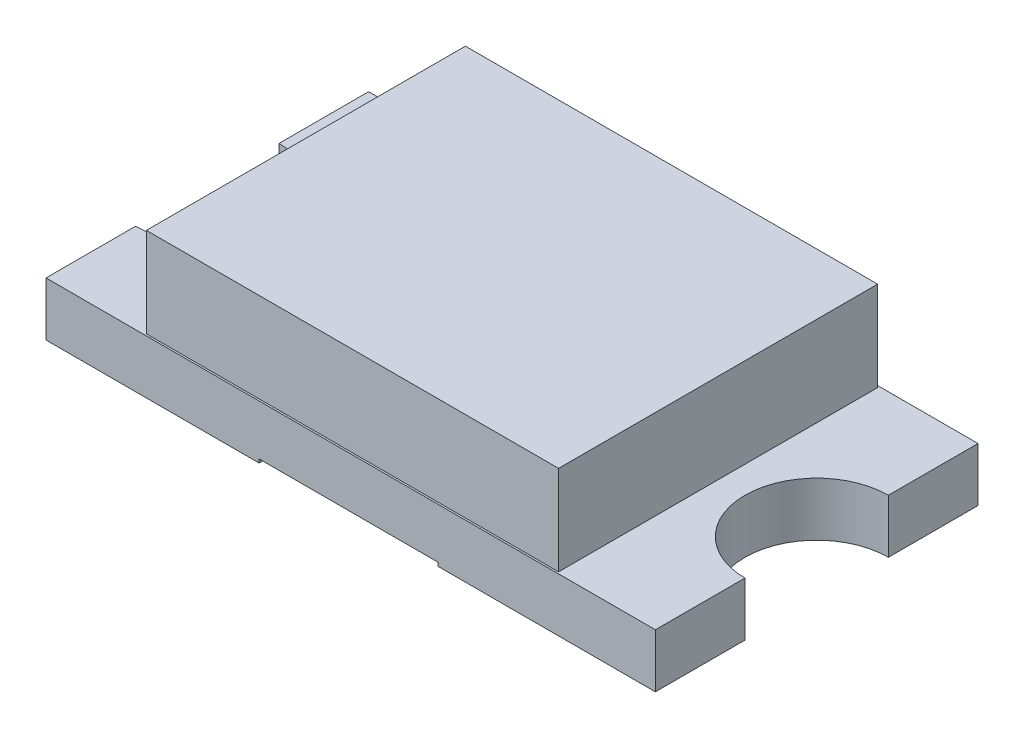
from build123d import *

# Parameters (mm, degrees)
SKETCH1_W           = 1.7
SKETCH1_H           = 0.9
BOSS_EXTRUDE1_DEPTH = 0.15
SKETCH2_R           = 0.2
CUT_EXTRUDE1_DEPTH  = 1.15
SKETCH3_W           = 1.15
SKETCH3_H           = 0.89
BOSS_EXTRUDE3_DEPTH = 0.25
SKETCH4_W           = 0.499334855
SKETCH4_H           = 0.9
CUT_EXTRUDE2_DEPTH  = 0.01


with BuildPart() as part:
    # Sketch1 → Boss-Extrude1 (new body)
    with BuildSketch(Plane(origin=(0, 0, 0), x_dir=(1, 0, 0), z_dir=(0, 1, 0))):
        Rectangle(SKETCH1_W, SKETCH1_H)
    extrude(amount=BOSS_EXTRUDE1_DEPTH)

    # Sketch2 → Cut-Extrude1 (cut, through all)
    with BuildSketch(Plane(origin=(0, 0.15, 0), x_dir=(1, 0, 0), z_dir=(0, 1, 0))):
        with Locations((-0.85, 0)):
            Circle(SKETCH2_R)
        with Locations((0.85, 0)):
            Circle(SKETCH2_R)
    extrude(amount=-CUT_EXTRUDE1_DEPTH, mode=Mode.SUBTRACT)

    # Sketch3 → Boss-Extrude3 (add)
    with BuildSketch(Plane(origin=(0, 0.15, 0), x_dir=(1, 0, 0), z_dir=(0, 1, 0))):
        Rectangle(SKETCH3_W, SKETCH3_H)
    extrude(amount=BOSS_EXTRUDE3_DEPTH)

    # Sketch4 → Cut-Extrude2 (cut)
    with BuildSketch(Plane.XZ):
        with Locations((-0.00596787, 0)):
            Rectangle(SKETCH4_W, SKETCH4_H)
    extrude(amount=-CUT_EXTRUDE2_DEPTH, mode=Mode.SUBTRACT)


solid = part.part
